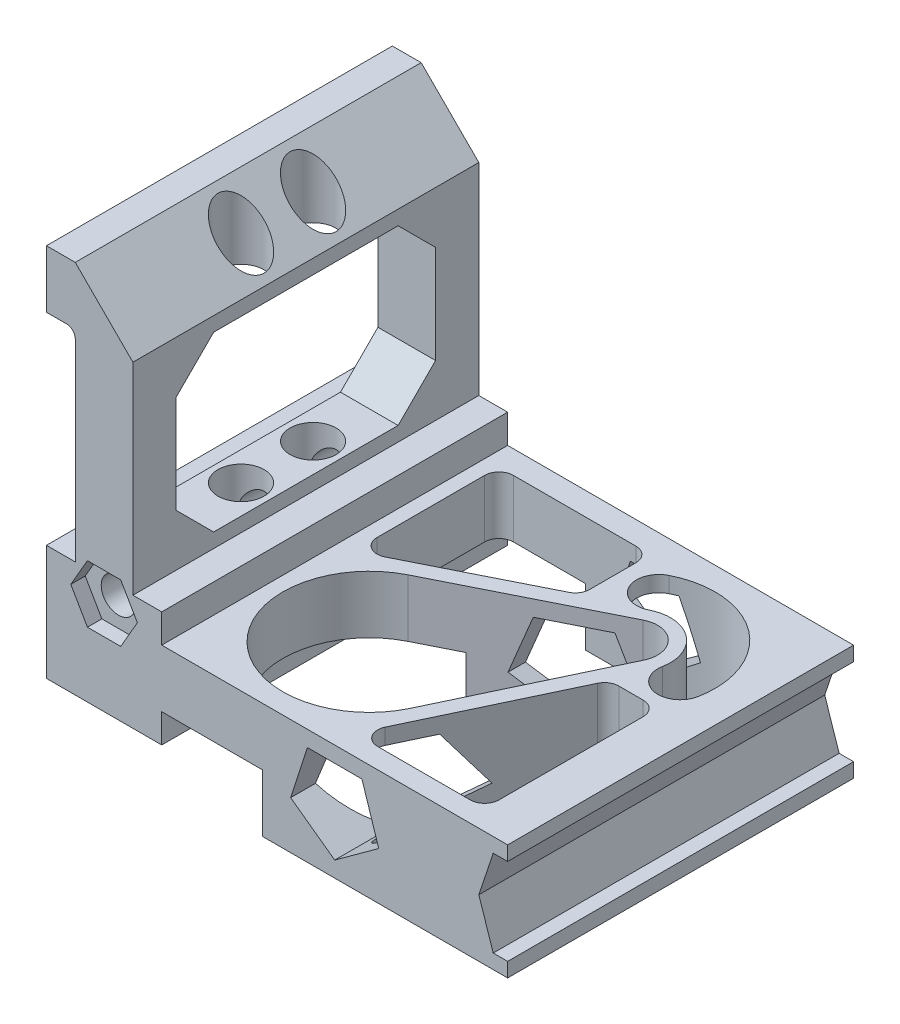
from build123d import *

# Parameters (mm, degrees)
SKETCH1_R           = 7.62
BOSS_EXTRUDE1_DEPTH = 76.2
CUT_EXTRUDE1_DEPTH  = 51.8
CUT_EXTRUDE2_DEPTH  = 39.1
SKETCH4_R           = 10.16
CUT_EXTRUDE3_DEPTH  = 166.1
CUT_EXTRUDE4_DEPTH  = 4.445
CUT_EXTRUDE5_DEPTH  = 6.35


with BuildPart() as part:
    # Sketch1 → Boss-Extrude1 (new body, symmetric)
    with BuildSketch(Plane.XY):
        with BuildLine():
            Line((0, 0), (0, 50.8))
            Line((0, 50.8), (12.7, 50.8))
            Line((12.7, 50.8), (12.7, 135.89))
            ThreePointArc((12.7, 135.89), (11.584076836, 138.584076836), (8.89, 139.7))
            Line((8.89, 139.7), (0, 139.7))
            Line((0, 139.7), (0, 165.1))
            Line((0, 165.1), (12.7, 165.1))
            Line((12.7, 165.1), (38.1, 139.7))
            Line((38.1, 139.7), (38.1, 50.8))
            Line((38.1, 50.8), (50.8, 50.8))
            Line((50.8, 50.8), (50.8, 38.1))
            Line((50.8, 38.1), (203.2, 38.1))
            Line((203.2, 38.1), (203.2, 31.75))
            Line((203.2, 31.75), (196.85, 31.75))
            Line((196.85, 31.75), (190.5, 12.7))
            Line((190.5, 12.7), (196.85, -6.35))
            Line((196.85, -6.35), (203.2, -6.35))
            Line((203.2, -6.35), (203.2, -12.7))
            Line((203.2, -12.7), (95.25, -12.7))
            Line((95.25, -12.7), (95.25, 12.7))
            Line((95.25, 12.7), (50.8, 12.7))
            Line((50.8, 12.7), (50.8, 0))
            Line((50.8, 0), (0, 0))
        make_face()
        with Locations((25.4, 41.275)):
            Circle(SKETCH1_R, mode=Mode.SUBTRACT)
        Polygon((146.408669031, 8.298741154), (138.995217137, 31.115), (115.004782863, 31.115), (107.591330969, 8.298741154), (127, -5.802482309), align=None, mode=Mode.SUBTRACT)
    extrude(amount=BOSS_EXTRUDE1_DEPTH, both=True)

    # Sketch2 → Cut-Extrude1 (cut, through all)
    with BuildSketch(Plane(origin=(0, 38.1, 0), x_dir=(1, 0, 0), z_dir=(0, 1, 0))):
        with BuildLine():
            Line((57.15, 59.69), (57.15, 12.310112434))
            ThreePointArc((57.15, 12.310112434), (60.162452878, 6.907957382), (66.341584002, 6.631388955))
            Line((66.341584002, 6.631388955), (120.316584002, 33.640011057))
            ThreePointArc((120.316584002, 33.640011057), (122.877155052, 35.981187414), (123.825, 39.318734537))
            Line((123.825, 39.318734537), (123.825, 59.69))
            ThreePointArc((123.825, 59.69), (121.965128061, 64.180128061), (117.475, 66.04))
            Line((117.475, 66.04), (63.5, 66.04))
            ThreePointArc((63.5, 66.04), (59.009871939, 64.180128061), (57.15, 59.69))
        make_face()
        with BuildLine():
            Line((78.20049599, 4.862340879), (147.285148797, 39.431702264))
            ThreePointArc((147.285148797, 39.431702264), (160.392932197, 37.380552912), (162.731634589, 24.321009641))
            Line((162.731634589, 24.321009641), (129.688781962, -45.506634528))
            ThreePointArc((129.688781962, -45.506634528), (68.606892677, -56.445176375), (78.20049599, 4.862340879))
        make_face()
        with BuildLine():
            Line((131.290134658, -58.243894245), (161.338708783, 5.256105755))
            ThreePointArc((161.338708783, 5.256105755), (163.681799397, 7.905154776), (167.078505776, 8.89))
            Line((167.078505776, 8.89), (177.8, 8.89))
            ThreePointArc((177.8, 8.89), (182.290128061, 7.030128061), (184.15, 2.54))
            Line((184.15, 2.54), (184.15, -60.96))
            ThreePointArc((184.15, -60.96), (182.290128061, -65.450128061), (177.8, -67.31))
            Line((177.8, -67.31), (137.029931652, -67.31))
            ThreePointArc((137.029931652, -67.31), (131.664776876, -64.35670638), (131.290134658, -58.243894245))
        make_face()
        with BuildLine():
            ThreePointArc((188.57162547, 22.277294118), (174.627718402, 58.576263546), (135.906341971, 62.140352941))
            ThreePointArc((135.906341971, 62.140352941), (131.513776952, 48.932212079), (144.721917814, 44.539647059))
            ThreePointArc((144.721917814, 44.539647059), (162.747386153, 42.880501996), (169.238515305, 25.982705882))
            ThreePointArc((169.238515305, 25.982705882), (177.052364505, 14.463444917), (188.57162547, 22.277294118))
        make_face()
    extrude(amount=-CUT_EXTRUDE1_DEPTH, mode=Mode.SUBTRACT)

    # Sketch3 → Cut-Extrude2 (cut, through all)
    with BuildSketch(Plane(origin=(38.1, 0, 0), x_dir=(0, 0, -1), z_dir=(1, 0, 0))):
        Polygon((-40.64, 133.35), (40.64, 133.35), (57.15, 116.84), (57.15, 73.66), (40.64, 57.15), (-40.64, 57.15), (-57.15, 73.66), (-57.15, 116.84), align=None)
    extrude(amount=-CUT_EXTRUDE2_DEPTH, mode=Mode.SUBTRACT)

    # Sketch4 → Cut-Extrude3 (cut, through all)
    with BuildSketch(Plane.XZ):
        with Locations((25.4, 15.875)):
            Circle(SKETCH4_R)
        with Locations((25.4, -15.875)):
            Circle(SKETCH4_R)
    extrude(amount=-CUT_EXTRUDE3_DEPTH, mode=Mode.SUBTRACT)

    # Sketch6 → Cut-Extrude4 (cut)
    with BuildSketch(Plane.XZ):
        Polygon((25.4, 0.762), (36.086504784, 5.188495216), (40.513, 15.875), (36.086504784, 26.561504784), (25.4, 30.988), (14.713495216, 26.561504784), (10.287, 15.875), (14.713495216, 5.188495216), align=None)
        Polygon((25.4, -30.988), (36.086504784, -26.561504784), (40.513, -15.875), (36.086504784, -5.188495216), (25.4, -0.762), (14.713495216, -5.188495216), (10.287, -15.875), (14.713495216, -26.561504784), align=None)
    extrude(amount=-CUT_EXTRUDE4_DEPTH, mode=Mode.SUBTRACT)

    # Sketch7 → Cut-Extrude5 (cut)
    with BuildSketch(Plane.XY.offset(76.2)):
        Polygon((40.064696837, 41.275), (32.732348419, 53.975), (18.067651581, 53.975), (10.735303163, 41.275), (18.067651581, 28.575), (32.732348419, 28.575), align=None)
    cut_extrude5 = extrude(amount=-CUT_EXTRUDE5_DEPTH, mode=Mode.SUBTRACT)

    # Mirror1: Cut-Extrude5 across plane
    add(cut_extrude5.mirror(Plane.XY), mode=Mode.SUBTRACT)


solid = part.part
